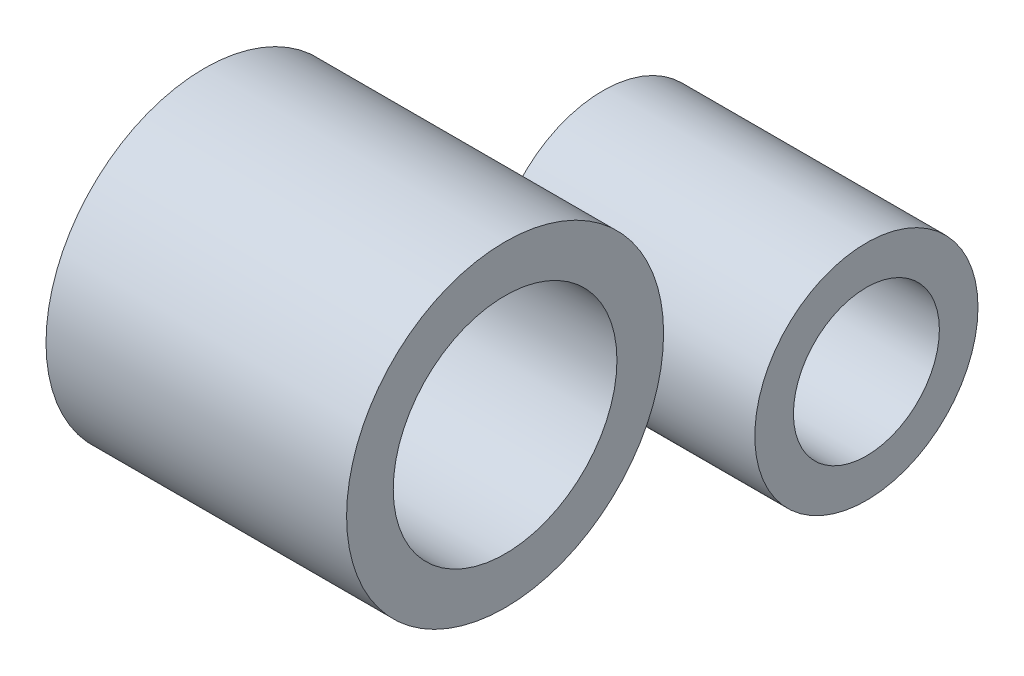
from build123d import *

# Parameters (mm, degrees)
SKETCH2_R           = 27.102495449
BOSS_EXTRUDE1_DEPTH = 64
SKETCH3_R           = 38.493502763
BOSS_EXTRUDE2_DEPTH = 73
SKETCH7_R           = 17.722141742
CUT_EXTRUDE1_DEPTH  = 95
SKETCH8_R           = 27.165719082
CUT_EXTRUDE2_DEPTH  = 95


with BuildPart() as part:
    # Sketch2 → Boss-Extrude1 (new body)
    with BuildSketch(Plane(origin=(0, 0, 0), x_dir=(0, 0, -1), z_dir=(1, 0, 0))):
        Circle(SKETCH2_R)
    extrude(amount=BOSS_EXTRUDE1_DEPTH)

    # Sketch7 → Cut-Extrude1 (cut)
    with BuildSketch(Plane.ZY):
        Circle(SKETCH7_R)
    extrude(amount=-CUT_EXTRUDE1_DEPTH, mode=Mode.SUBTRACT)


with BuildPart() as body_2:
    # Sketch3 → Boss-Extrude2 (new body)
    with BuildSketch(Plane(origin=(0, 0, 0), x_dir=(0, 0, -1), z_dir=(1, 0, 0))):
        with Locations((-96.74416718, 41.705825758)):
            Circle(SKETCH3_R)
    extrude(amount=BOSS_EXTRUDE2_DEPTH)

    # Sketch8 → Cut-Extrude2 (cut)
    with BuildSketch(Plane.ZY):
        with Locations((96.74416718, 41.705825758)):
            Circle(SKETCH8_R)
    extrude(amount=-CUT_EXTRUDE2_DEPTH, mode=Mode.SUBTRACT)


solid = Compound([part.part, body_2.part])
